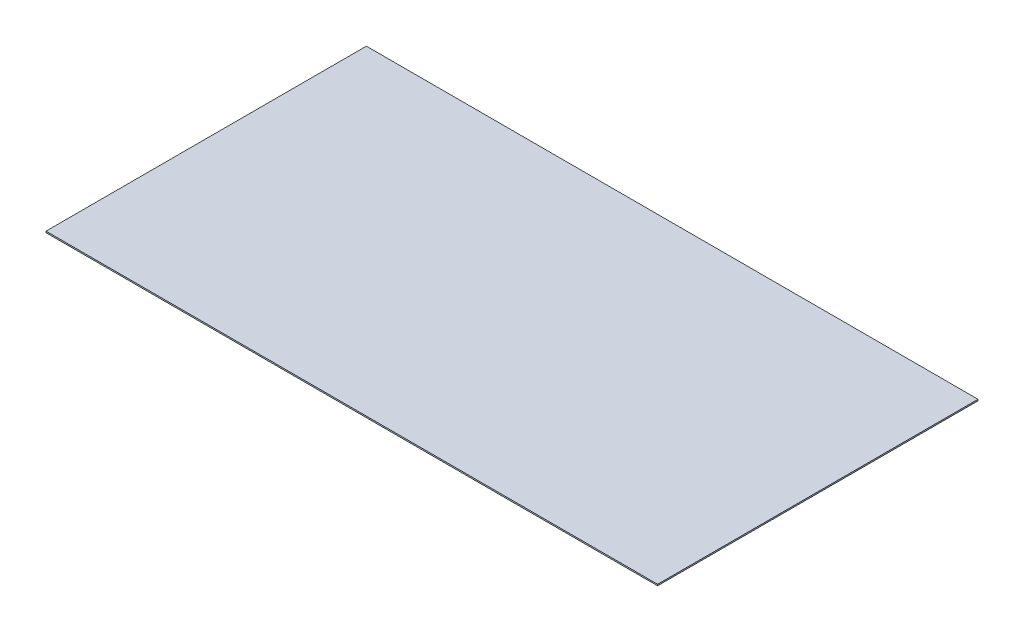
from build123d import *

# Parameters (mm, degrees)
SKETCH1_W           = 2100
SKETCH1_H           = 1100
BOSS_EXTRUDE1_DEPTH = 4.7625


with BuildPart() as part:
    # Sketch1 → Boss-Extrude1 (new body)
    with BuildSketch(Plane(origin=(0, 0, 0), x_dir=(1, 0, 0), z_dir=(0, 1, 0))):
        Rectangle(SKETCH1_W, SKETCH1_H)
    extrude(amount=BOSS_EXTRUDE1_DEPTH)


solid = part.part
